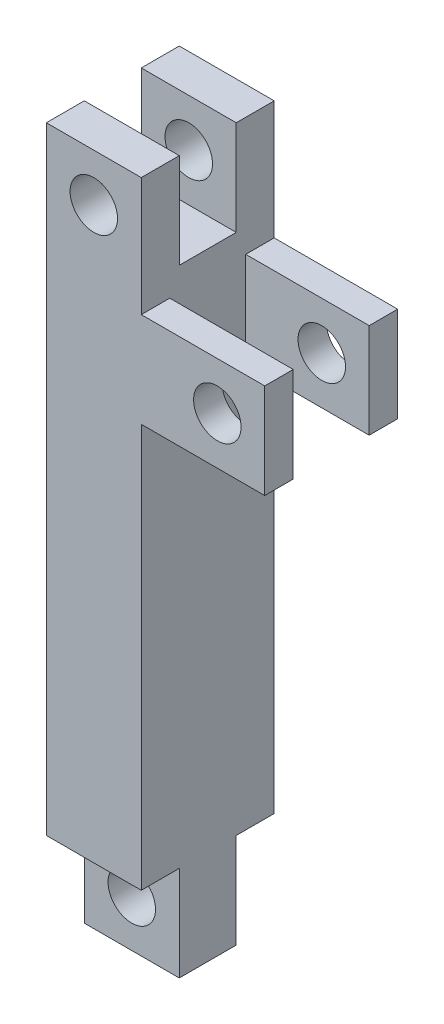
from build123d import *

# Parameters (mm, degrees)
SKETCH_1_W                = 10
SKETCH_1_H                = 14
EXTRUDE_1_DEPTH           = 32.5
SKETCH_7_W                = 13
SKETCH_7_H                = 10
EXTRUDE_3_DEPTH           = 7
SKETCH_8_W                = 13
SKETCH_8_H                = 10
CUT_EXTRUDE_3_DEPTH       = 4
SKETCH_10_R               = 2.5
CUT_EXTRUDE_4_DEPTH       = 8
CUT_EXTRUDE_4_DEPTH_BACK  = 8
SKETCH_14_W               = 10
SKETCH_14_H               = 10
CUT_EXTRUDE_8_DEPTH       = 3
SKETCH_15_W               = 10
SKETCH_15_H               = 10
EXTRUDE_4_DEPTH           = 3
SKETCH_16_R               = 2.5
CUT_EXTRUDE_9_DEPTH       = 8
CUT_EXTRUDE_9_DEPTH_BACK  = 8
SKETCH_17_R               = 2.5
CUT_EXTRUDE_10_DEPTH      = 8
CUT_EXTRUDE_10_DEPTH_BACK = 8


with BuildPart() as part:
    # 草图1 → 凸台-拉伸1 (new body, symmetric)
    with BuildSketch(Plane(origin=(0, 0, 0), x_dir=(1, 0, 0), z_dir=(0, 1, 0))):
        Rectangle(SKETCH_1_W, SKETCH_1_H)
    extrude(amount=EXTRUDE_1_DEPTH, both=True)

    # 草图7 → 凸台-拉伸3 (add, symmetric)
    with BuildSketch(Plane.XY):
        with Locations((11.5, 15)):
            Rectangle(SKETCH_7_W, SKETCH_7_H)
    extrude(amount=EXTRUDE_3_DEPTH, both=True)

    # 草图8 → 切除-拉伸3 (cut, symmetric)
    with BuildSketch(Plane.XY):
        with Locations((11.5, 15)):
            Rectangle(SKETCH_8_W, SKETCH_8_H)
    extrude(amount=CUT_EXTRUDE_3_DEPTH, both=True, mode=Mode.SUBTRACT)

    # 草图10 → 切除-拉伸4 (cut, two sides)
    with BuildSketch(Plane.XY) as cut_extrude_4_sk:
        with Locations((13.005535268, 15)):
            Circle(SKETCH_10_R)
    extrude(amount=CUT_EXTRUDE_4_DEPTH, mode=Mode.SUBTRACT)
    extrude(cut_extrude_4_sk.sketch, amount=-CUT_EXTRUDE_4_DEPTH_BACK, mode=Mode.SUBTRACT)

    # 草图14 → 切除-拉伸8 (cut, symmetric)
    with BuildSketch(Plane.XY):
        with Locations((0, 27.5)):
            Rectangle(SKETCH_14_W, SKETCH_14_H)
    extrude(amount=CUT_EXTRUDE_8_DEPTH, both=True, mode=Mode.SUBTRACT)

    # 草图15 → 凸台-拉伸4 (add, symmetric)
    with BuildSketch(Plane.XY):
        with Locations((0, -37.5)):
            Rectangle(SKETCH_15_W, SKETCH_15_H)
    extrude(amount=EXTRUDE_4_DEPTH, both=True)

    # 草图16 → 切除-拉伸9 (cut, two sides)
    with BuildSketch(Plane.XY) as cut_extrude_9_sk:
        with Locations((0, 27.5)):
            Circle(SKETCH_16_R)
    extrude(amount=CUT_EXTRUDE_9_DEPTH, mode=Mode.SUBTRACT)
    extrude(cut_extrude_9_sk.sketch, amount=-CUT_EXTRUDE_9_DEPTH_BACK, mode=Mode.SUBTRACT)

    # 草图17 → 切除-拉伸10 (cut, two sides)
    with BuildSketch(Plane.XY) as cut_extrude_10_sk:
        with Locations((0, -37.5)):
            Circle(SKETCH_17_R)
    extrude(amount=CUT_EXTRUDE_10_DEPTH, mode=Mode.SUBTRACT)
    extrude(cut_extrude_10_sk.sketch, amount=-CUT_EXTRUDE_10_DEPTH_BACK, mode=Mode.SUBTRACT)


solid = part.part
